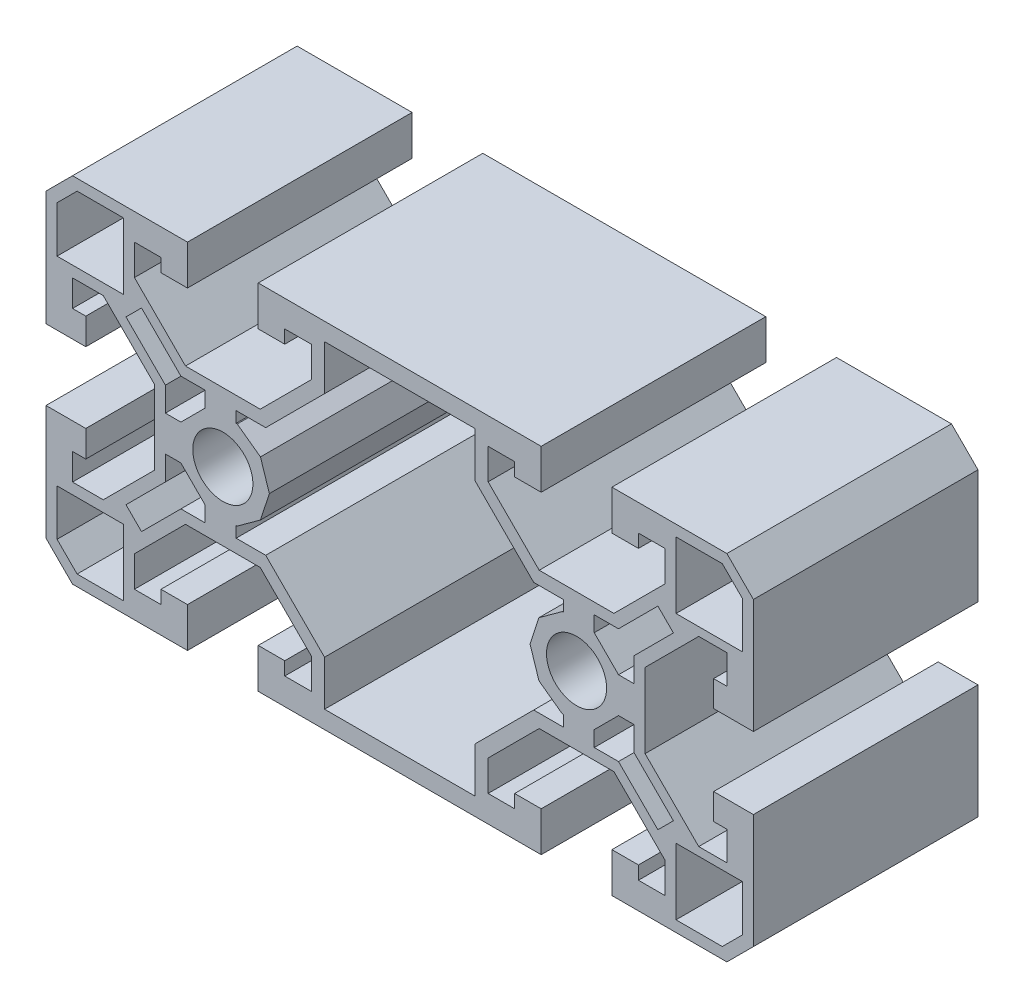
from build123d import *

# Parameters (mm, degrees)
SKETCH1_R      = 3.4
EXTRUDE1_DEPTH = 25.4


with BuildPart() as part:
    # Sketch1 → Extrude1 (new body)
    with BuildSketch(Plane.XY):
        Polygon((-367.383665724, -5.145535609), (-367.383665724, -8.620535609), (-370.383665724, -8.620535609), (-370.383665724, -7.120535609), (-373.383665724, -7.120535609), (-373.383665724, -11.620535609), (-341.383665724, -11.620535609), (-341.383665724, -7.120535609), (-344.383665724, -7.120535609), (-344.383665724, -8.620535609), (-347.383665724, -8.620535609), (-347.383665724, -5.145535609), (-341.608665724, 0.629464391), (-333.158665724, 0.629464391), (-327.383665724, -5.145535609), (-327.383665724, -8.620535609), (-330.383665724, -8.620535609), (-330.383665724, -7.120535609), (-333.383665724, -7.120535609), (-333.383665724, -11.620535609), (-320.383665724, -11.620535609), (-317.383665724, -8.620535609), (-317.383665724, 4.315964391), (-321.883665724, 4.315964391), (-321.883665724, 1.379464391), (-320.383665724, 1.379464391), (-320.383665724, -1.912635609), (-323.566565724, -1.912635609), (-329.633665724, 4.154464391), (-329.633665724, 12.604464391), (-323.566565724, 18.671564391), (-320.383665724, 18.671564391), (-320.383665724, 15.379464391), (-321.883665724, 15.379464391), (-321.883665724, 12.442964391), (-317.383665724, 12.442964391), (-317.383665724, 25.379464391), (-320.383665724, 28.379464391), (-333.383665724, 28.379464391), (-333.383665724, 23.879464391), (-330.383665724, 23.879464391), (-330.383665724, 25.379464391), (-327.383665724, 25.379464391), (-327.383665724, 21.904464391), (-333.158665724, 16.129464391), (-341.608665724, 16.129464391), (-347.383665724, 21.904464391), (-347.383665724, 25.379464391), (-344.383665724, 25.379464391), (-344.383665724, 23.879464391), (-341.383665724, 23.879464391), (-341.383665724, 28.379464391), (-373.383665724, 28.379464391), (-373.383665724, 23.879464391), (-370.383665724, 23.879464391), (-370.383665724, 25.379464391), (-367.383665724, 25.379464391), (-367.383665724, 21.904464391), (-373.158665724, 16.129464391), (-381.608665724, 16.129464391), (-387.383665724, 21.904464391), (-387.383665724, 25.379464391), (-384.383665724, 25.379464391), (-384.383665724, 23.879464391), (-381.383665724, 23.879464391), (-381.383665724, 28.379464391), (-394.383665724, 28.379464391), (-397.383665724, 25.379464391), (-397.383665724, 12.379464391), (-392.883665724, 12.379464391), (-392.883665724, 15.379464391), (-394.383665724, 15.379464391), (-394.383665724, 18.379464391), (-390.908665724, 18.379464391), (-385.133665724, 12.604464391), (-385.133665724, 4.154464391), (-390.908665724, -1.620535609), (-394.383665724, -1.620535609), (-394.383665724, 1.379464391), (-392.883665724, 1.379464391), (-392.883665724, 4.379464391), (-397.383665724, 4.379464391), (-397.383665724, -8.620535609), (-394.383665724, -11.620535609), (-381.383665724, -11.620535609), (-381.383665724, -7.120535609), (-384.383665724, -7.120535609), (-384.383665724, -8.620535609), (-387.383665724, -8.620535609), (-387.383665724, -5.145535609), (-381.608665724, 0.629464391), (-373.158665724, 0.629464391), align=None)
        with Locations((-337.383665724, 8.379464391)):
            Circle(SKETCH1_R, mode=Mode.SUBTRACT)
        with Locations((-377.383665724, 8.379464391)):
            Circle(SKETCH1_R, mode=Mode.SUBTRACT)
        Polygon((-373.130411724, 11.469634391), (-372.126354724, 8.379464391), (-373.130411724, 5.289294391), (-375.759067724, 3.379464391), (-375.883665724, 3.379464391), (-375.883665724, 2.129464391), (-372.537345724, 2.129464391), (-365.883665724, -4.524215609), (-365.883665724, -9.620535609), (-348.883665724, -9.620535609), (-348.883665724, -4.524215609), (-342.229985724, 2.129464391), (-338.883665724, 2.129464391), (-338.883665724, 3.379464391), (-339.008263724, 3.379464391), (-341.636919724, 5.289294391), (-342.640976724, 8.379464391), (-341.636919724, 11.469634391), (-339.008263724, 13.379464391), (-338.883665724, 13.379464391), (-338.883665724, 14.629464391), (-342.229985724, 14.629464391), (-348.883665724, 21.283144391), (-348.883665724, 26.379464391), (-365.883665724, 26.379464391), (-365.883665724, 21.283144391), (-372.537345724, 14.629464391), (-375.883665724, 14.629464391), (-375.883665724, 13.379464391), (-375.759067724, 13.379464391), align=None, mode=Mode.SUBTRACT)
        Polygon((-382.126432724, 14.879464391), (-386.581320724, 19.334352391), (-388.338553724, 17.577119391), (-383.883665724, 13.122231391), (-383.883665724, 10.379464391), (-382.129453724, 10.379464391), (-379.383665724, 13.125252391), (-379.383665724, 14.879464391), align=None, mode=Mode.SUBTRACT)
        Polygon((-332.640898724, 1.879464391), (-328.186010724, -2.575423609), (-326.428777724, -0.818190609), (-330.883665724, 3.636697391), (-330.883665724, 6.379464391), (-332.637877724, 6.379464391), (-335.383665724, 3.633676391), (-335.383665724, 1.879464391), align=None, mode=Mode.SUBTRACT)
        Polygon((-383.883665724, 3.636697391), (-388.338553724, -0.818190609), (-386.581320724, -2.575423609), (-382.126432724, 1.879464391), (-379.383665724, 1.879464391), (-379.383665724, 3.633676391), (-382.129453724, 6.379464391), (-383.883665724, 6.379464391), align=None, mode=Mode.SUBTRACT)
        Polygon((-330.883665724, 13.122231391), (-326.428777724, 17.577119391), (-328.186010724, 19.334352391), (-332.640898724, 14.879464391), (-335.383665724, 14.879464391), (-335.383665724, 13.125252391), (-332.637877724, 10.379464391), (-330.883665724, 10.379464391), align=None, mode=Mode.SUBTRACT)
        Polygon((-393.865898724, 27.129464391), (-396.133665724, 24.861697391), (-396.133665724, 19.629464391), (-388.633665724, 19.629464391), (-388.633665724, 27.129464391), align=None, mode=Mode.SUBTRACT)
        Polygon((-320.901432724, -10.370535609), (-318.633665724, -8.102768609), (-318.633665724, -2.870535609), (-326.133665724, -2.870535609), (-326.133665724, -10.370535609), align=None, mode=Mode.SUBTRACT)
        Polygon((-396.133665724, -2.870535609), (-396.133665724, -8.102768609), (-393.865898724, -10.370535609), (-388.633665724, -10.370535609), (-388.633665724, -2.870535609), align=None, mode=Mode.SUBTRACT)
        Polygon((-318.633665724, 19.629464391), (-318.633665724, 24.861697391), (-320.901432724, 27.129464391), (-326.133665724, 27.129464391), (-326.133665724, 19.629464391), align=None, mode=Mode.SUBTRACT)
    extrude(amount=EXTRUDE1_DEPTH)


solid = part.part
